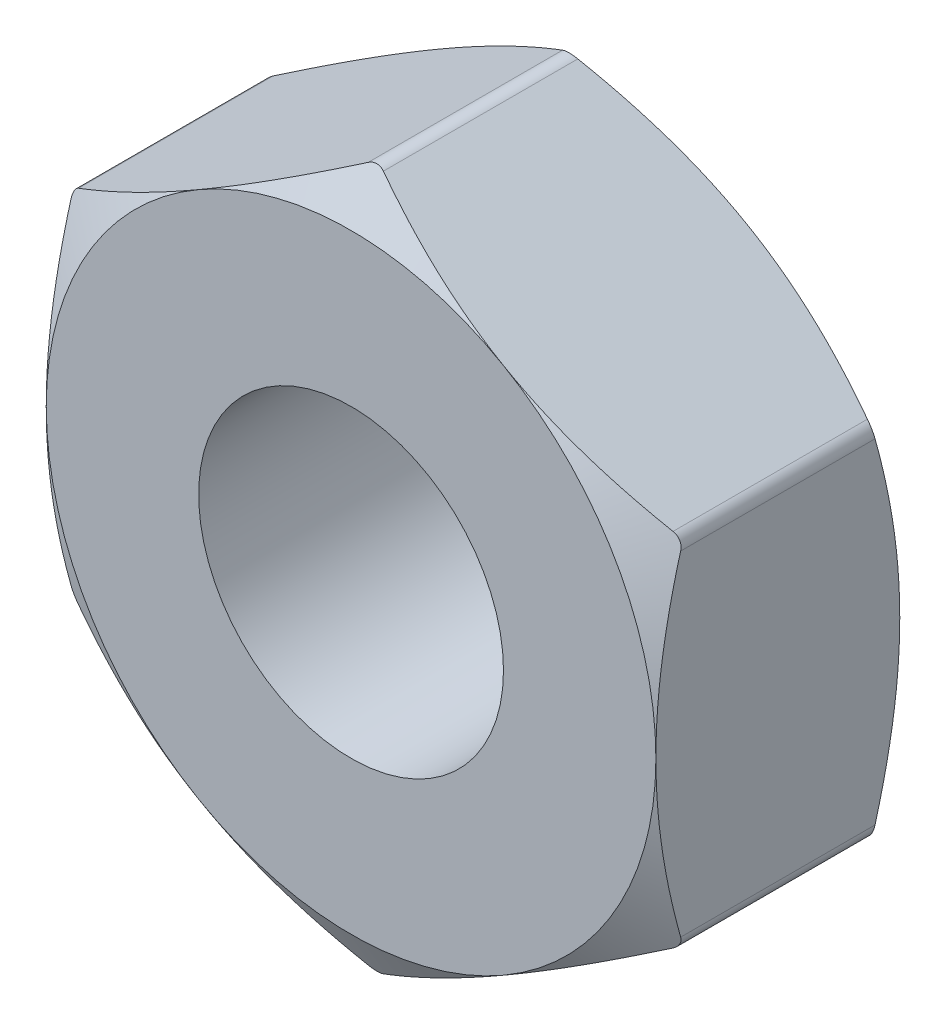
from build123d import *

# Parameters (mm, degrees)
BOSS_EXTRUDE2_DEPTH     = 0.8
CUT_EXTRUDE4_DEPTH      = 4.158058475
CUT_EXTRUDE4_DEPTH_BACK = 4.158058475
SKETCH16_R              = 1
SKETCH7_OUTSIDE_W       = 22.674
SKETCH7_OUTSIDE_H       = 23.292
SKETCH7_OUTSIDE_R       = 2
CUT_EXTRUDE5_DEPTH      = 4.448671242
CUT_EXTRUDE5_DRAFT      = -60
MIRROR4_COPY_1_SKETCH_W = 22.674
MIRROR4_COPY_1_SKETCH_H = 23.292
MIRROR4_COPY_1_SKETCH_R = 2
MIRROR4_COPY_1_DEPTH    = 4.448671242
MIRROR4_COPY_1_DRAFT    = -60
FILLET2_R               = 0.1


with BuildPart() as part:
    # Sketch15 → Boss-Extrude2 (new, symmetric)
    with BuildSketch(Plane.XY):
        Polygon((0, 2.309401077), (-2, 1.154700538), (-2, -1.154700538), (0, -2.309401077), (2, -1.154700538), (2, 1.154700538), align=None)
    extrude(amount=BOSS_EXTRUDE2_DEPTH, both=True)

    # Sketch16 → Cut-Extrude4 (cut, two sides: drawn at the far end of the back side and taken through both)
    with BuildSketch(Plane.XY.offset(-CUT_EXTRUDE4_DEPTH_BACK)):
        Circle(SKETCH16_R)
    extrude(amount=CUT_EXTRUDE4_DEPTH + CUT_EXTRUDE4_DEPTH_BACK, mode=Mode.SUBTRACT)


with BuildPart() as cut_extrude5_tool:
    # Sketch7 outside → Cut-Extrude5 (with draft: the straight prism first)
    with BuildSketch(Plane.XY.offset(0.8)):
        Rectangle(SKETCH7_OUTSIDE_W, SKETCH7_OUTSIDE_H)
        Circle(SKETCH7_OUTSIDE_R, mode=Mode.SUBTRACT)
    extrude(amount=-CUT_EXTRUDE5_DEPTH)
    # Cut-Extrude5: the draft: its side faces are tilted about the plane it starts from
    cut_extrude5_sides = [cut_extrude5_tool.faces().sort_by_distance(p)[0] for p in [
        (0, -11.646, -1.424335621),
        (11.337, 0, -1.424335621),
        (0, 11.646, -1.424335621),
        (-11.337, 0, -1.424335621),
        (-2, 0, -1.424335621),
    ]]
    draft(cut_extrude5_sides, Plane.XY.offset(0.8), CUT_EXTRUDE5_DRAFT)


with BuildPart() as part_1:
    add(part.part)

    # Cut-Extrude5: cut by cut_extrude5_tool
    add(cut_extrude5_tool.part, mode=Mode.SUBTRACT)


with BuildPart() as mirror4_copy_1_tool:
    # Mirror4 copy 1 sketch → Mirror4 copy 1 (with draft: the straight prism first)
    with BuildSketch(Plane(origin=(0, 0, -0.8), x_dir=(1, 0, 0), z_dir=(0, 0, -1))):
        Rectangle(MIRROR4_COPY_1_SKETCH_W, MIRROR4_COPY_1_SKETCH_H)
        Circle(MIRROR4_COPY_1_SKETCH_R, mode=Mode.SUBTRACT)
    extrude(amount=-MIRROR4_COPY_1_DEPTH)
    # Mirror4 copy 1: the draft: its side faces are tilted about the plane it starts from
    mirror4_copy_1_sides = [mirror4_copy_1_tool.faces().sort_by_distance(p)[0] for p in [
        (0, -11.646, 1.424335621),
        (11.337, 0, 1.424335621),
        (0, 11.646, 1.424335621),
        (-11.337, 0, 1.424335621),
        (-2, 0, 1.424335621),
    ]]
    draft(mirror4_copy_1_sides, Plane(origin=(0, 0, -0.8), x_dir=(1, 0, 0), z_dir=(0, 0, -1)), MIRROR4_COPY_1_DRAFT)


with BuildPart() as part_2:
    add(part_1.part)

    # Mirror4 copy 1: cut by mirror4_copy_1_tool
    add(mirror4_copy_1_tool.part, mode=Mode.SUBTRACT)

    # Fillet2
    fillet2_edges = [part_2.edges().sort_by_distance(p)[0] for p in [
        (-2, 1.154700538, 0),
        (-2, -1.154700538, 0),
        (0, -2.309401077, 0),
        (2, -1.154700538, 0),
        (2, 1.154700538, 0),
        (0, 2.309401077, 0),
    ]]
    fillet(fillet2_edges, radius=FILLET2_R)


solid = part_2.part
